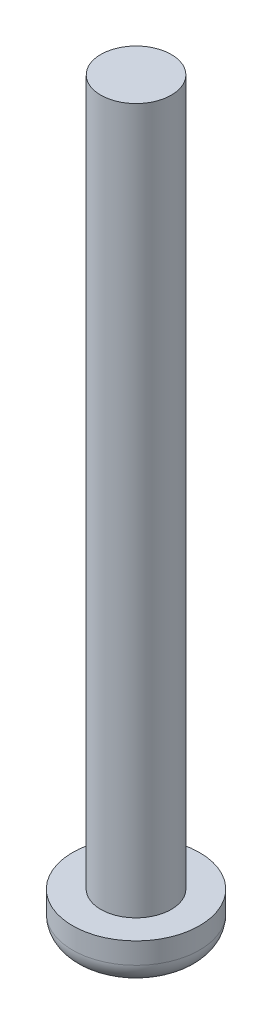
from build123d import *

# Parameters (mm, degrees)
SKETCH1_R           = 0.5
BOSS_EXTRUDE1_DEPTH = 10
SKETCH2_R           = 0.9
BOSS_EXTRUDE2_DEPTH = 0.6
FILLET1_R           = 0.3


with BuildPart() as part:
    # Sketch1 → Boss-Extrude1 (new body)
    with BuildSketch(Plane(origin=(0, 0, 0), x_dir=(1, 0, 0), z_dir=(0, 1, 0))):
        Circle(SKETCH1_R)
    extrude(amount=BOSS_EXTRUDE1_DEPTH)

    # Sketch2 → Boss-Extrude2 (add)
    with BuildSketch(Plane.XZ):
        Circle(SKETCH2_R)
    extrude(amount=BOSS_EXTRUDE2_DEPTH)

    # Fillet1
    fillet1_edges = [part.edges().sort_by_distance(p)[0] for p in [
        (-0.9, -0.6, 0),
    ]]
    fillet(fillet1_edges, radius=FILLET1_R)


solid = part.part
